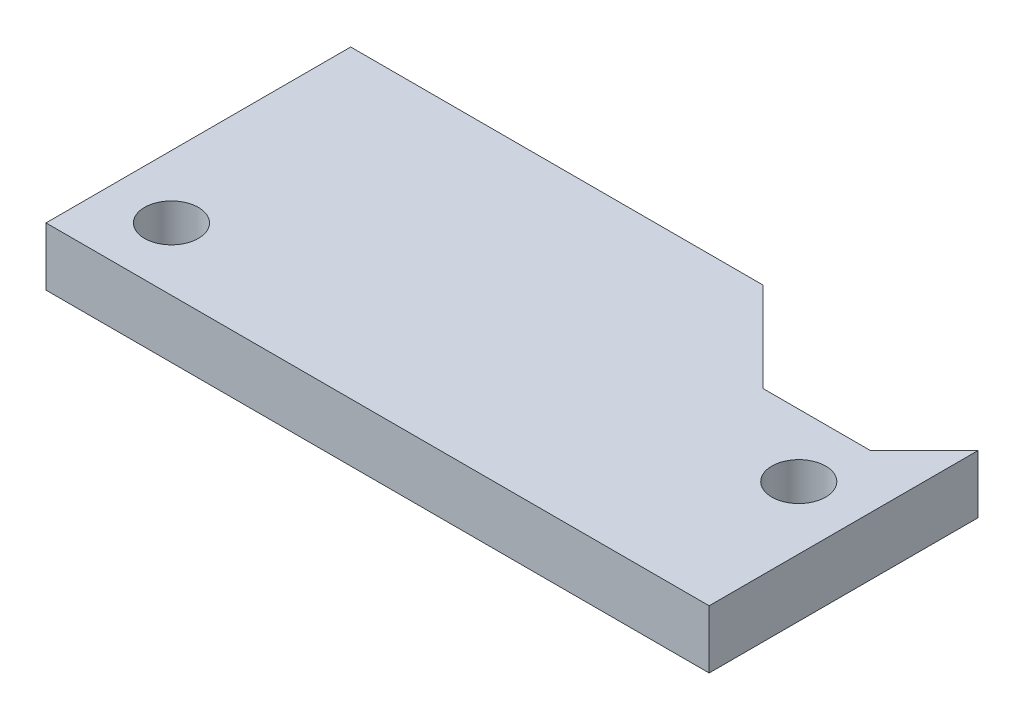
from build123d import *

# Parameters (mm, degrees)
SKETCH1_R           = 1.5025
BOSS_EXTRUDE1_DEPTH = 3.25


with BuildPart() as part:
    # Sketch1 → Boss-Extrude1 (new body)
    with BuildSketch(Plane(origin=(0, 0, 0), x_dir=(1, 0, 0), z_dir=(0, 1, 0))):
        Polygon((-18.5, 8.5), (4.5, 8.5), (9.5, 3.5), (15.5, 3.5), (18.5, 6.5), (18.5, -8.5), (-18.5, -8.5), align=None)
        with Locations((-15, -5)):
            Circle(SKETCH1_R, mode=Mode.SUBTRACT)
        with Locations((15, 0)):
            Circle(SKETCH1_R, mode=Mode.SUBTRACT)
    extrude(amount=BOSS_EXTRUDE1_DEPTH)


solid = part.part
